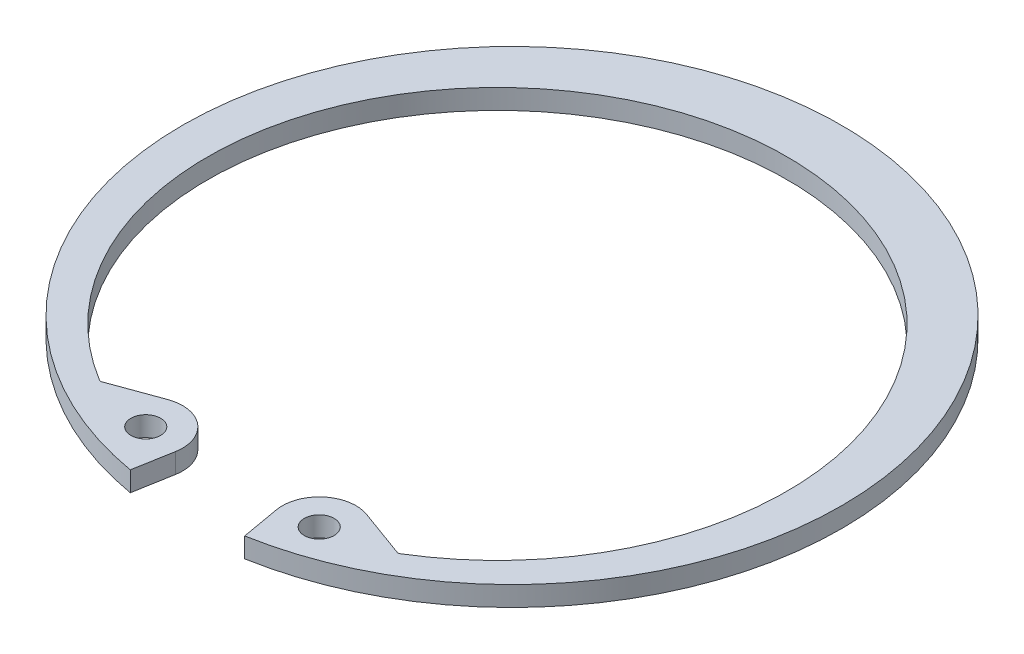
from build123d import *

# Parameters (mm, degrees)
SKETCH2_R      = 1.1811
EXTRUDE1_DEPTH = 1.5748
FILLET1_R      = 0.254


with BuildPart() as part:
    # Sketch2 → Extrude1 (new body)
    with BuildSketch(Plane(origin=(0, 0, 0), x_dir=(1, 0, 0), z_dir=(0, 1, 0))):
        with BuildLine():
            Line((4.534162297, -25.7145122), (3.994863547, -22.655997005))
            ThreePointArc((3.994863547, -22.655997005), (4.993904385, -19.91115486), (7.870527832, -19.403928533))
            Line((7.870527832, -19.403928533), (11.810483262, -20.837955033))
            ThreePointArc((11.810483262, -20.837955033), (0, 21.7932), (-11.810483262, -20.837955033))
            Line((-11.810483262, -20.837955033), (-7.870527832, -19.403928533))
            ThreePointArc((-7.870527832, -19.403928533), (-4.993904385, -19.91115486), (-3.994863547, -22.655997005))
            Line((-3.994863547, -22.655997005), (-4.534162297, -25.7145122))
            ThreePointArc((-4.534162297, -25.7145122), (0, 26.1112), (4.534162297, -25.7145122))
        make_face()
        with Locations((6.871486993, -22.148770678)):
            Circle(SKETCH2_R, mode=Mode.SUBTRACT)
        with Locations((-6.871486993, -22.148770678)):
            Circle(SKETCH2_R, mode=Mode.SUBTRACT)
    extrude(amount=-EXTRUDE1_DEPTH)

    # Fillet1
    fillet1_edges = [part.edges().sort_by_distance(p)[0] for p in [
        (11.810483262, -0.7874, 20.837955033),
        (-11.810483262, -0.7874, 20.837955033),
    ]]
    fillet(fillet1_edges, radius=FILLET1_R)


solid = part.part
